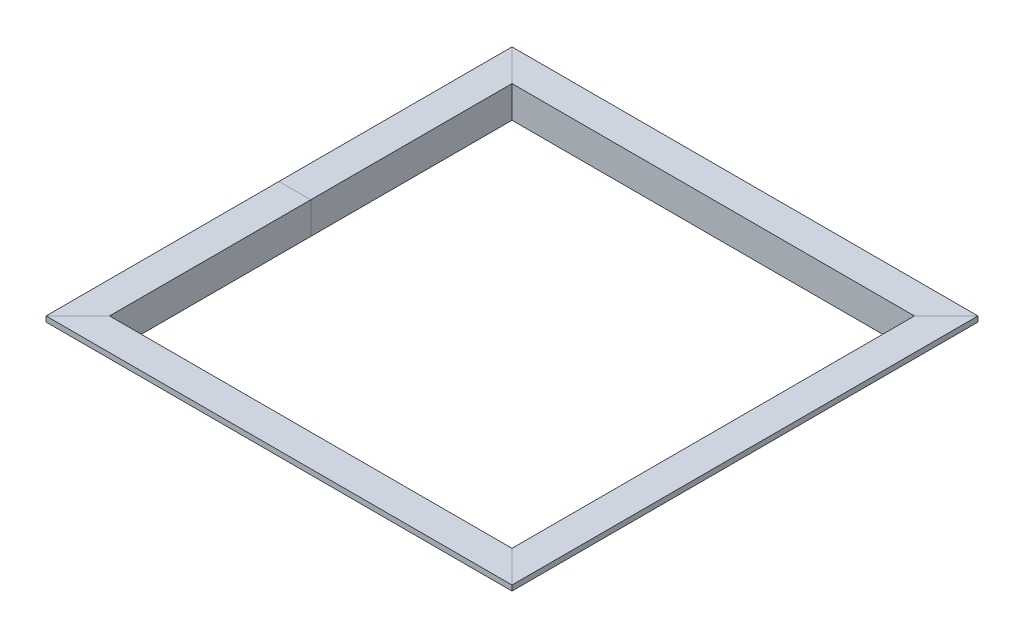
from build123d import *


with BuildPart() as part:
    # Sweep1: sweep along a path in Sketch1
    with BuildLine(Plane(origin=(0, 0, 0), x_dir=(1, 0, 0), z_dir=(0, 1, 0))) as sweep1_path:
        Line((279.4, -279.4), (-279.4, -279.4))
        Line((-279.4, -279.4), (-279.4, 279.4))
        Line((-279.4, 279.4), (279.4, 279.4))
        Line((279.4, 279.4), (279.4, -279.4))
    # Sketch2 → Sweep1 (sweep)
    with BuildSketch(Plane.XY):
        Polygon((-279.4, 0), (-241.3, 0), (-241.3, -38.1), (-247.65, -38.1), (-247.65, -6.35), (-279.4, -6.35), align=None)
    sweep(path=sweep1_path.line, transition=Transition.RIGHT)


solid = part.part
